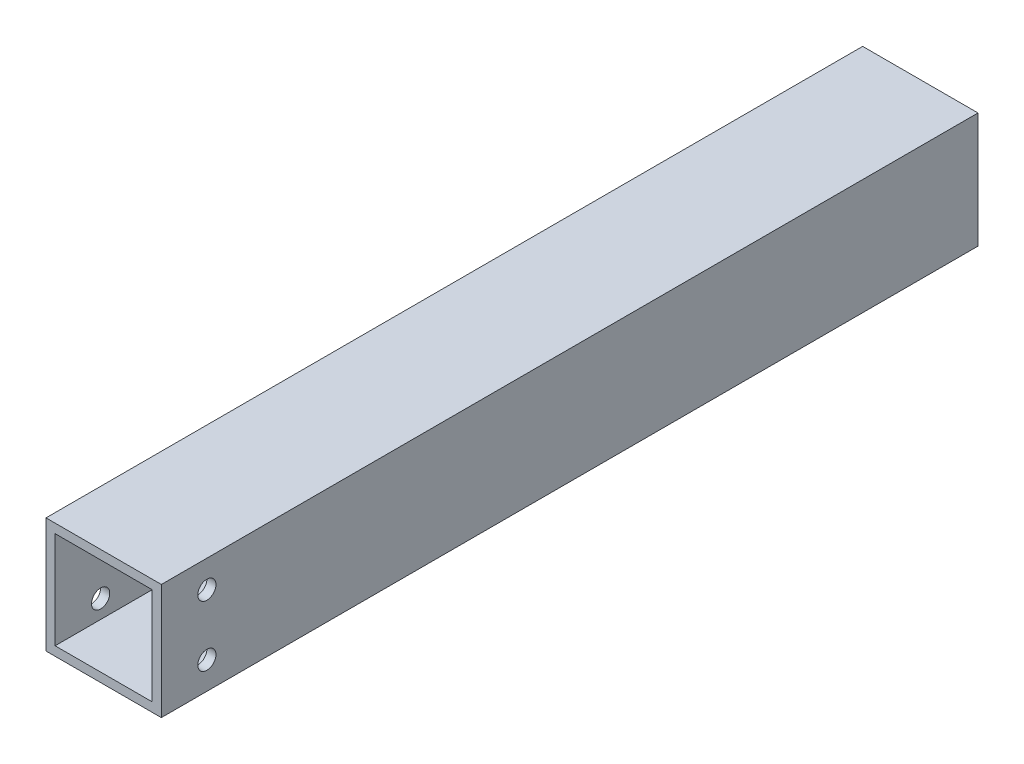
from build123d import *

# Parameters (mm, degrees)
SKETCH1_W               = 38
SKETCH1_H               = 38
SKETCH1_W_2             = 32
SKETCH1_H_2             = 32
BOSS_EXTRUDE1_DEPTH     = 269.06
SKETCH2_R               = 3
CUT_EXTRUDE1_DEPTH      = 1
CUT_EXTRUDE1_DEPTH_BACK = 39


with BuildPart() as part:
    # Sketch1 → Boss-Extrude1 (new body)
    with BuildSketch(Plane.XY):
        Rectangle(SKETCH1_W, SKETCH1_H)
        Rectangle(SKETCH1_W_2, SKETCH1_H_2, mode=Mode.SUBTRACT)
    extrude(amount=BOSS_EXTRUDE1_DEPTH)

    # Sketch2 → Cut-Extrude1 (cut, two sides)
    with BuildSketch(Plane(origin=(19, 0, 0), x_dir=(0, 0, -1), z_dir=(1, 0, 0))) as cut_extrude1_sk:
        with Locations((-254.06, 10)):
            Circle(SKETCH2_R)
        with Locations((-254.06, -10)):
            Circle(SKETCH2_R)
    extrude(amount=CUT_EXTRUDE1_DEPTH, mode=Mode.SUBTRACT)
    extrude(cut_extrude1_sk.sketch, amount=-CUT_EXTRUDE1_DEPTH_BACK, mode=Mode.SUBTRACT)


solid = part.part
